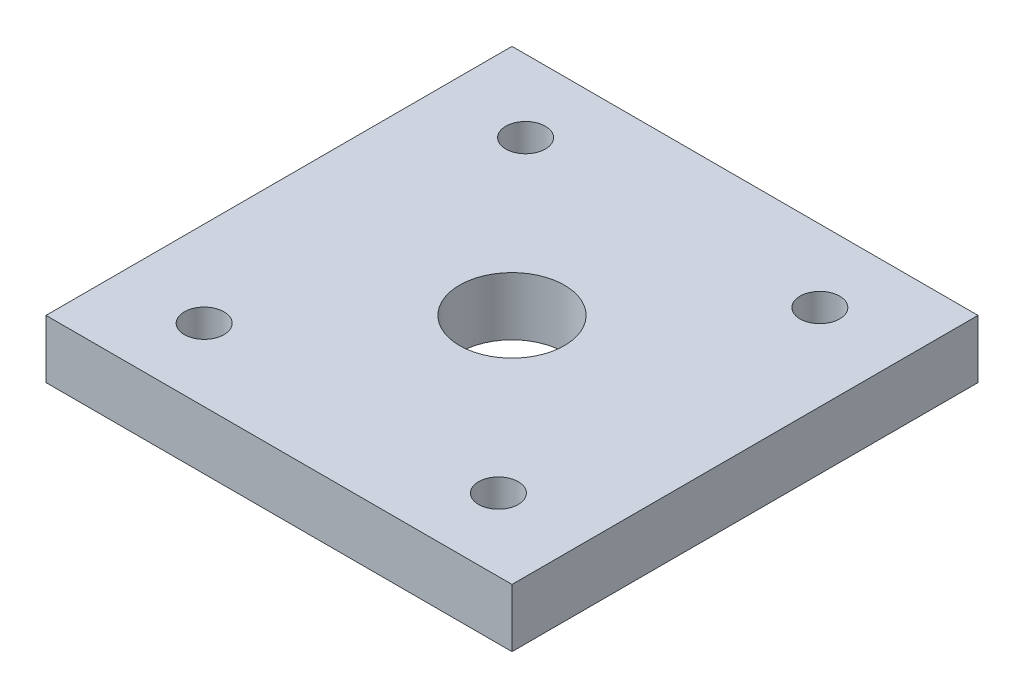
from build123d import *

# Parameters (mm, degrees)
CROQUIS1_W              = 40
CROQUIS1_H              = 40
CROQUIS1_R              = 4.5
SALIENTE_EXTRUIR1_DEPTH = 5
CROQUIS2_R              = 1.7
CORTAR_EXTRUIR1_DEPTH   = 10


with BuildPart() as part:
    # Croquis1 → Saliente-Extruir1 (new body)
    with BuildSketch(Plane(origin=(0, 0, 0), x_dir=(1, 0, 0), z_dir=(0, 1, 0))):
        Rectangle(CROQUIS1_W, CROQUIS1_H)
        Circle(CROQUIS1_R, mode=Mode.SUBTRACT)
    extrude(amount=SALIENTE_EXTRUIR1_DEPTH)

    # Croquis2 → Cortar-Extruir1 (cut)
    with BuildSketch(Plane.XZ):
        with Locations((12.628756813, -13.795283125)):
            Circle(CROQUIS2_R)
        with Locations((12.628756813, 13.795283125)):
            Circle(CROQUIS2_R)
        with Locations((-12.628756813, 13.795283125)):
            Circle(CROQUIS2_R)
        with Locations((-12.628756813, -13.795283125)):
            Circle(CROQUIS2_R)
    extrude(amount=-CORTAR_EXTRUIR1_DEPTH, mode=Mode.SUBTRACT)


solid = part.part
